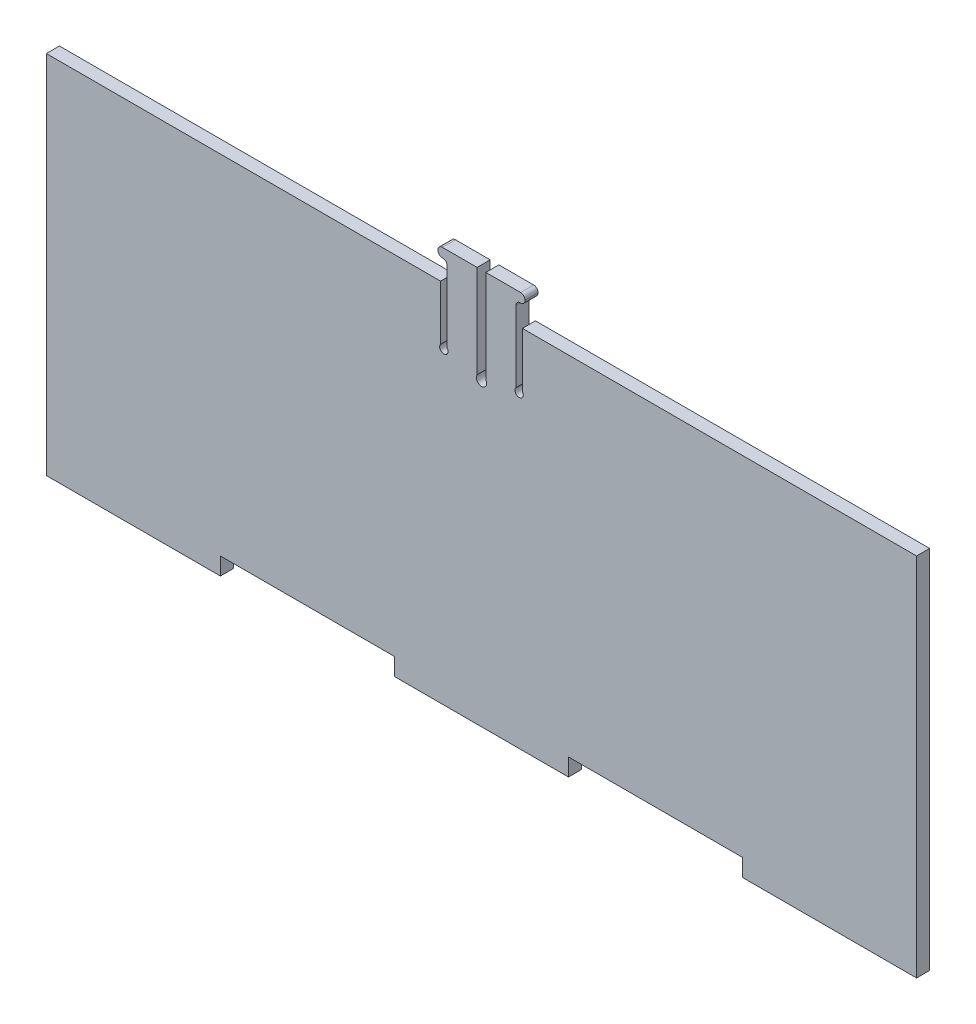
from build123d import *

# Parameters (mm, degrees)
BOSS_EXTRUDE1_DEPTH = 3


with BuildPart() as part:
    # Sketch1 → Boss-Extrude1 (new body)
    with BuildSketch(Plane.XY):
        with BuildLine():
            Line((-20, -42), (-20, -38))
            Line((-20, -38), (-60, -38))
            Line((-60, -38), (-60, -42))
            Line((-60, -42), (-100, -42))
            Line((-100, -42), (-100, 42))
            Line((-100, 42), (-9.4, 42))
            Line((-9.4, 42), (-9.4, 29.437955396))
            ThreePointArc((-9.4, 29.437955396), (-8.65, 27.879616867), (-7.9, 29.437955396))
            Line((-7.9, 29.437955396), (-7.9, 45.839266813))
            ThreePointArc((-7.9, 45.839266813), (-8.192893219, 46.546373594), (-8.9, 46.839266813))
            Line((-8.9, 46.839266813), (-9, 46.839266813))
            ThreePointArc((-9, 46.839266813), (-9.707106781, 47.132160032), (-10, 47.839266813))
            Line((-10, 47.839266813), (-10, 47.939266813))
            ThreePointArc((-10, 47.939266813), (-9.707106781, 48.646373594), (-9, 48.939266813))
            Line((-9, 48.939266813), (-1, 48.939266813))
            Line((-1, 48.939266813), (-1, 27.583372359))
            ThreePointArc((-1, 27.583372359), (0, 25.749782911), (1, 27.583372359))
            Line((1, 27.583372359), (1, 48.939266813))
            Line((1, 48.939266813), (9, 48.939266813))
            ThreePointArc((9, 48.939266813), (9.707106781, 48.646373594), (10, 47.939266813))
            Line((10, 47.939266813), (10, 47.839266813))
            ThreePointArc((10, 47.839266813), (9.707106781, 47.132160032), (9, 46.839266813))
            Line((9, 46.839266813), (8.9, 46.839266813))
            ThreePointArc((8.9, 46.839266813), (8.192893219, 46.546373594), (7.9, 45.839266813))
            Line((7.9, 45.839266813), (7.9, 29.437955396))
            ThreePointArc((7.9, 29.437955396), (8.65, 27.879616867), (9.4, 29.437955396))
            Line((9.4, 29.437955396), (9.4, 42))
            Line((9.4, 42), (100, 42))
            Line((100, 42), (100, -42))
            Line((100, -42), (60, -42))
            Line((60, -42), (60, -38))
            Line((60, -38), (20, -38))
            Line((20, -38), (20, -42))
            Line((20, -42), (-20, -42))
        make_face()
    extrude(amount=BOSS_EXTRUDE1_DEPTH)


solid = part.part
